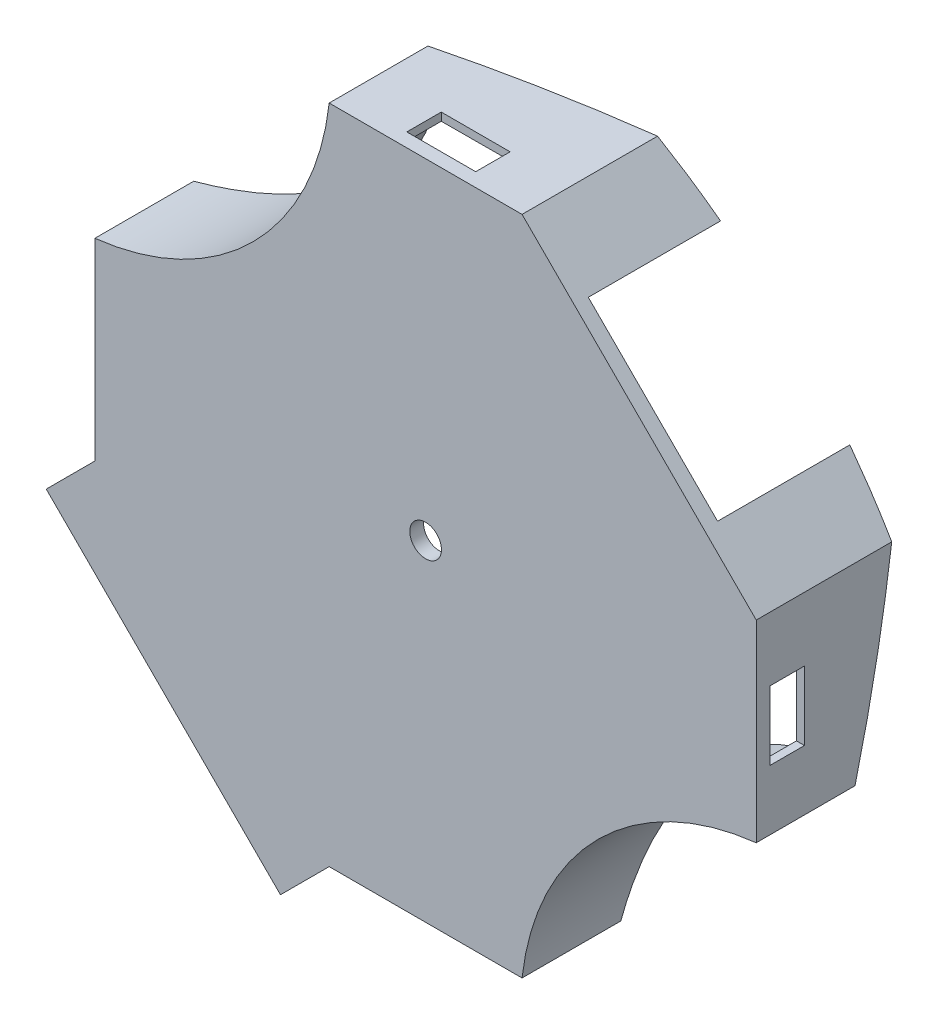
from build123d import *

# Parameters (mm, degrees)
SKETCH1_R           = 2.299249708
BOSS_EXTRUDE1_DEPTH = 2
BOSS_EXTRUDE2_DEPTH = 25
CUT_EXTRUDE1_DEPTH  = 5
CUT_EXTRUDE2_DEPTH  = 122.722871427


with BuildPart() as part:
    # Sketch1 → Boss-Extrude1 (new body)
    with BuildSketch(Plane.XY):
        with BuildLine():
            Line((-50.442352941, -22.916302521), (-22.442352941, -22.916302521))
            ThreePointArc((-22.442352941, -22.916302521), (-11.414384755, 0.055729293), (11.557647059, 11.083697479))
            Line((11.557647059, 11.083697479), (11.557647059, 39.083697479))
            Line((11.557647059, 39.083697479), (-22.442352941, 73.083697479))
            Line((-22.442352941, 73.083697479), (-50.442352941, 73.083697479))
            ThreePointArc((-50.442352941, 73.083697479), (-61.477304412, 50.118648949), (-84.442352941, 39.083697479))
            Line((-84.442352941, 39.083697479), (-84.442352941, 11.083697479))
            Line((-84.442352941, 11.083697479), (-91.513420753, 4.012629667))
            Line((-91.513420753, 4.012629667), (-57.513420753, -29.987370333))
            Line((-57.513420753, -29.987370333), (-50.442352941, -22.916302521))
        make_face()
        with Locations((-36.442352941, 25.083697479)):
            Circle(SKETCH1_R, mode=Mode.SUBTRACT)
    extrude(amount=BOSS_EXTRUDE1_DEPTH)

    # Sketch2 → Boss-Extrude2 (add)
    with BuildSketch(Plane.XY.offset(2)):
        with BuildLine():
            Line((11.557647059, 11.083697479), (11.557647059, 39.083697479))
            Line((11.557647059, 39.083697479), (3.941530535, 46.699814003))
            Line((3.941530535, 46.699814003), (3.144174906, 45.902458373))
            Line((3.144174906, 45.902458373), (10.470077714, 38.576555565))
            Line((10.470077714, 38.576555565), (10.361931826, 12.13145892))
            ThreePointArc((10.361931826, 12.13145892), (-12.239549802, 0.88089434), (-23.490114382, -21.720587289))
            Line((-23.490114382, -21.720587289), (-49.935211027, -21.828733177))
            Line((-49.935211027, -21.828733177), (-50.442352941, -22.916302521))
            Line((-50.442352941, -22.916302521), (-22.442352941, -22.916302521))
            ThreePointArc((-22.442352941, -22.916302521), (-11.407401471, 0.048746009), (11.557647059, 11.083697479))
        make_face()
        with BuildLine():
            Line((-22.442352941, 73.083697479), (-50.442352941, 73.083697479))
            ThreePointArc((-50.442352941, 73.083697479), (-61.477304412, 50.118648949), (-84.442352941, 39.083697479))
            Line((-84.442352941, 39.083697479), (-84.442352941, 11.083697479))
            Line((-84.442352941, 11.083697479), (-83.354783597, 11.590839393))
            Line((-83.354783597, 11.590839393), (-83.246637709, 38.035936038))
            ThreePointArc((-83.246637709, 38.035936038), (-60.64515608, 49.286500618), (-49.394591501, 71.887982247))
            Line((-49.394591501, 71.887982247), (-22.949494855, 71.996128135))
            Line((-22.949494855, 71.996128135), (-15.623592047, 64.670225326))
            Line((-15.623592047, 64.670225326), (-14.826236418, 65.467580955))
            Line((-14.826236418, 65.467580955), (-22.442352941, 73.083697479))
        make_face()
    extrude(amount=-BOSS_EXTRUDE2_DEPTH)

    # Sketch3 → Cut-Extrude1 (cut)
    with BuildSketch(Plane(origin=(0, 0, 0), x_dir=(-1, 0, 0), z_dir=(0, 0, -1))):
        Polygon((31.712662704, -21.754212985), (31.712662704, -22.916302521), (41.712662704, -22.916302521), (41.712662704, -21.79510748), (41.712662704, -21.572636028), (31.712662704, -21.531741532), align=None)
        Polygon((-10.395557523, 29.813387716), (-11.557647059, 29.813387716), (-11.557647059, 19.813387716), (-10.436452018, 19.813387716), (-10.213980565, 19.813387716), (-10.17308607, 29.813387716), align=None)
        Polygon((41.172043178, 71.921607943), (41.172043178, 73.083697479), (31.172043178, 73.083697479), (31.172043178, 71.962502438), (31.172043178, 71.740030985), (41.172043178, 71.69913649), align=None)
        Polygon((83.280263405, 20.354007242), (84.442352941, 20.354007242), (84.442352941, 30.354007242), (83.3211579, 30.354007242), (83.098686448, 30.354007242), (83.057791952, 20.354007242), align=None)
    extrude(amount=CUT_EXTRUDE1_DEPTH, mode=Mode.SUBTRACT)

    # Sketch4 → Cut-Extrude2 (cut, through all)
    with BuildSketch(Plane(origin=(25.320672269, 25.320672269, 0), x_dir=(0.707106781, -0.707106781, 0), z_dir=(0.707106781, 0.707106781, 0))):
        with BuildLine():
            Line((-87.346107905, 12.335462167), (-87.346107905, 23))
            Line((-87.346107905, 23), (0.335132962, 23))
            Line((0.335132962, 23), (0.335132962, 12.335462167))
            add(Edge.make_bspline(
                [(-87.346107905, 12.335462167), (-59.446253938, 22.367177976), (-27.564721006, 22.367177976), (0.335132962, 12.335462167)],
                knots=[0, 0, 0, 0, 1, 1, 1, 1], degree=3))
        make_face()
    extrude(amount=-CUT_EXTRUDE2_DEPTH, mode=Mode.SUBTRACT)


solid = part.part
